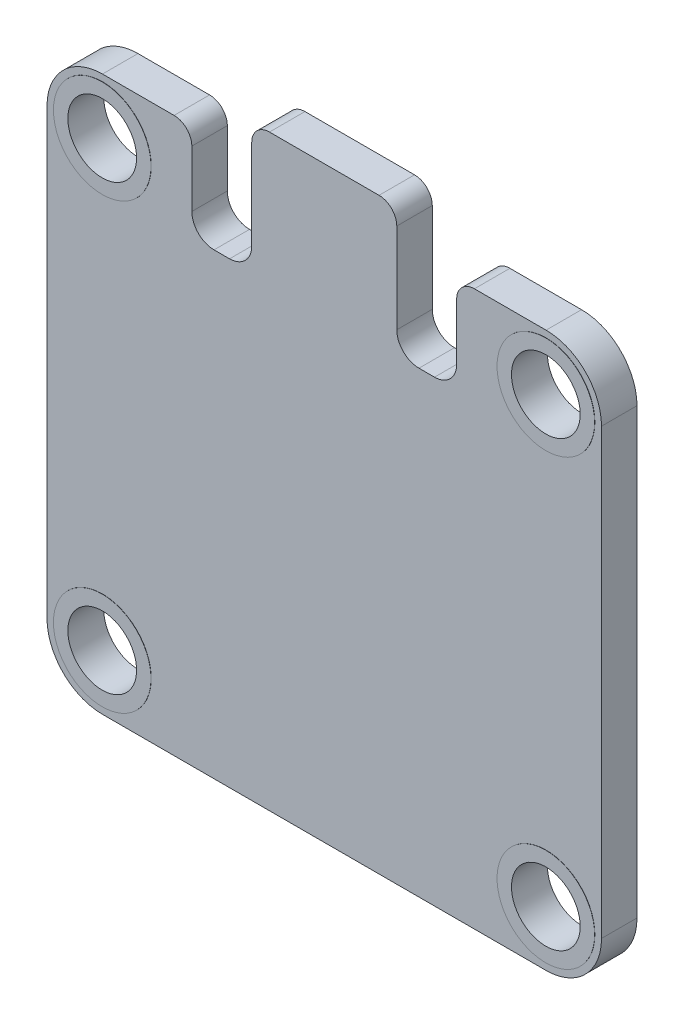
from build123d import *

# Parameters (mm, degrees)
SKETCH2_W                                  = 25
SKETCH2_H                                  = 25
BOSS_EXTRUDE1_MODULE_PCB_DEPTH             = 1.6
FILLET1_CORNERS_R                          = 2.5
SKETCH3_R                                  = 1.55
CUT_EXTRUDE1_FIRST_MH_DEPTH                = 1.6
SKETCH4_R                                  = 2.2
SKETCH4_R_2                                = 1.55
BOSS_EXTRUDE2_PTH_FOR_FIRST_MH_DEPTH       = 0.01
MIRROR2_SECOND_MH_PTH_COPY_1_SKETCH_R      = 2.2
MIRROR2_SECOND_MH_PTH_COPY_1_SKETCH_R_2    = 1.55
MIRROR2_SECOND_MH_PTH_COPY_1_DEPTH         = 0.01
MIRROR3_REMAINING_MH_PTH_COPY_1_SKETC_R    = 1.55
MIRROR3_REMAINING_MH_PTH_COPY_1_DEPTH      = 1.6
MIRROR3_REMAINING_MH_PTH_COPY_2_SKETC_R    = 2.2
MIRROR3_REMAINING_MH_PTH_COPY_2_SKETC_R_2  = 1.55
MIRROR3_REMAINING_MH_PTH_COPY_2_DEPTH      = 0.01
MIRROR3_REMAINING_MH_PTH_COPY_3_SKETC_R    = 2.2
MIRROR3_REMAINING_MH_PTH_COPY_3_SKETC_R_2  = 1.55
MIRROR3_REMAINING_MH_PTH_COPY_3_DEPTH      = 0.01
MIRROR3_REMAINING_MH_PTH_COPY_4_SKETC_R    = 2.2
MIRROR3_REMAINING_MH_PTH_COPY_4_SKETC_R_2  = 1.55
MIRROR3_REMAINING_MH_PTH_COPY_4_DEPTH      = 0.01
BOSS_EXTRUDE1_REACH                        = 3.62
SKETCH5_W                                  = 6.54
SKETCH5_H                                  = 1.6
BOSS_EXTRUDE3_TIP_OF_EDGE_CONNECTOR_DEPTH  = 1.5
SKETCH6_W                                  = 2.7
SKETCH6_H                                  = 1.6
CUT_EXTRUDE2_SIDES_OF_EDGE_CONNECTOR_DEPTH = 4.35
FILLET2_TIP_OF_EDGE_CONNECTOR_R            = 0.8
FILLET3_BASE_OF_EDGE_CONNECTOR_R           = 1
FILLET4_ADJACENT_TO_EDGE_CONNECTOR_R       = 0.8


with BuildPart() as part:
    # Sketch2 → Boss-Extrude1 _module PCB (new body)
    with BuildSketch(Plane.XY):
        Rectangle(SKETCH2_W, SKETCH2_H)
    extrude(amount=BOSS_EXTRUDE1_MODULE_PCB_DEPTH)

    # Fillet1 _corners
    fillet1_corners_edges = [part.edges().sort_by_distance(p)[0] for p in [
        (12.5, -12.5, 0.8),
        (-12.5, -12.5, 0.8),
        (-12.5, 12.5, 0.8),
        (12.5, 12.5, 0.8),
    ]]
    fillet(fillet1_corners_edges, radius=FILLET1_CORNERS_R)

    # Sketch3 → Cut-Extrude1 _first MH (cut)
    with BuildSketch(Plane.XY):
        with Locations((10, 10)):
            Circle(SKETCH3_R)
    cut_extrude1_first_mh = extrude(amount=CUT_EXTRUDE1_FIRST_MH_DEPTH, mode=Mode.SUBTRACT)

    # Sketch4 → Boss-Extrude2 _PTH for first MH (add)
    with BuildSketch(Plane.XY):
        with Locations((10, 10)):
            Circle(SKETCH4_R)
        with Locations((10, 10)):
            Circle(SKETCH4_R_2, mode=Mode.SUBTRACT)
    boss_extrude2_pth_for_first_mh = extrude(amount=-BOSS_EXTRUDE2_PTH_FOR_FIRST_MH_DEPTH)

    # Mirror1 _PTH for first MH: Boss-Extrude2 _PTH for first MH across plane
    add(boss_extrude2_pth_for_first_mh.mirror(Plane.XY.offset(0.8)))

    # Mirror2 _second MH _ PTH: Cut-Extrude1 _first MH, Boss-Extrude2 _PTH for first MH across plane
    add(cut_extrude1_first_mh.mirror(Plane(origin=(0, 0, 0), x_dir=(0, 0, 1), z_dir=(1, 0, 0))), mode=Mode.SUBTRACT)
    add(boss_extrude2_pth_for_first_mh.mirror(Plane(origin=(0, 0, 0), x_dir=(0, 0, 1), z_dir=(1, 0, 0))))

    # Mirror2 _second MH _ PTH copy 1 sketch → Mirror2 _second MH _ PTH copy 1 (add)
    with BuildSketch(Plane(origin=(0, 0, 1.6), x_dir=(-1, 0, 0), z_dir=(0, 0, -1))):
        with Locations((10, 10)):
            Circle(MIRROR2_SECOND_MH_PTH_COPY_1_SKETCH_R)
        with Locations((10, 10)):
            Circle(MIRROR2_SECOND_MH_PTH_COPY_1_SKETCH_R_2, mode=Mode.SUBTRACT)
    extrude(amount=-MIRROR2_SECOND_MH_PTH_COPY_1_DEPTH)

    # Mirror3 _remaining MH _ PTH: Cut-Extrude1 _first MH, Boss-Extrude2 _PTH for first MH across plane
    add(cut_extrude1_first_mh.mirror(Plane.ZX), mode=Mode.SUBTRACT)
    add(boss_extrude2_pth_for_first_mh.mirror(Plane.ZX))

    # Mirror3 _remaining MH _ PTH copy 1 sketc → Mirror3 _remaining MH _ PTH copy 1 (cut)
    with BuildSketch(Plane(origin=(0, 0, 0), x_dir=(-1, 0, 0), z_dir=(0, 0, 1))):
        with Locations((10, 10)):
            Circle(MIRROR3_REMAINING_MH_PTH_COPY_1_SKETC_R)
    extrude(amount=MIRROR3_REMAINING_MH_PTH_COPY_1_DEPTH, mode=Mode.SUBTRACT)

    # Mirror3 _remaining MH _ PTH copy 2 sketc → Mirror3 _remaining MH _ PTH copy 2 (add)
    with BuildSketch(Plane(origin=(0, 0, 0), x_dir=(-1, 0, 0), z_dir=(0, 0, 1))):
        with Locations((10, 10)):
            Circle(MIRROR3_REMAINING_MH_PTH_COPY_2_SKETC_R)
        with Locations((10, 10)):
            Circle(MIRROR3_REMAINING_MH_PTH_COPY_2_SKETC_R_2, mode=Mode.SUBTRACT)
    extrude(amount=-MIRROR3_REMAINING_MH_PTH_COPY_2_DEPTH)

    # Mirror3 _remaining MH _ PTH copy 3 sketc → Mirror3 _remaining MH _ PTH copy 3 (add)
    with BuildSketch(Plane(origin=(0, 0, 1.6), x_dir=(-1, 0, 0), z_dir=(0, 0, -1))):
        with Locations((10, -10)):
            Circle(MIRROR3_REMAINING_MH_PTH_COPY_3_SKETC_R)
        with Locations((10, -10)):
            Circle(MIRROR3_REMAINING_MH_PTH_COPY_3_SKETC_R_2, mode=Mode.SUBTRACT)
    extrude(amount=-MIRROR3_REMAINING_MH_PTH_COPY_3_DEPTH)

    # Mirror3 _remaining MH _ PTH copy 4 sketc → Mirror3 _remaining MH _ PTH copy 4 (add)
    with BuildSketch(Plane(origin=(0, 0, 1.6), x_dir=(1, 0, 0), z_dir=(0, 0, -1))):
        with Locations((10, 10)):
            Circle(MIRROR3_REMAINING_MH_PTH_COPY_4_SKETC_R)
        with Locations((10, 10)):
            Circle(MIRROR3_REMAINING_MH_PTH_COPY_4_SKETC_R_2, mode=Mode.SUBTRACT)
    extrude(amount=-MIRROR3_REMAINING_MH_PTH_COPY_4_DEPTH)

    # Sketch7 → Boss-Extrude1 (add, up to next)
    with BuildSketch(Plane(origin=(0, 0, -0.01), x_dir=(-1, 0, 0), z_dir=(0, 0, -1)), mode=Mode.PRIVATE) as boss_extrude1_sk1:
        with BuildLine():
            Line((-10, -7.8), (-12.2, -7.8))
            Line((-12.2, -7.8), (-12.2, -10))
            ThreePointArc((-12.2, -10), (-11.555634919, -8.444365081), (-10, -7.8))
        make_face()
    boss_extrude1_tool1 = extrude(boss_extrude1_sk1.sketch, amount=-BOSS_EXTRUDE1_REACH, mode=Mode.PRIVATE) - part.part
    add(boss_extrude1_tool1.solids().sort_by_distance((11.708591, -8.291409, -0.01))[0])
    # Sketch7 → Boss-Extrude1 (add, up to next)
    with BuildSketch(Plane(origin=(0, 0, -0.01), x_dir=(-1, 0, 0), z_dir=(0, 0, -1)), mode=Mode.PRIVATE) as boss_extrude1_sk2:
        with BuildLine():
            Line((-10, -12.2), (-7.8, -12.2))
            Line((-7.8, -12.2), (-7.8, -10))
            ThreePointArc((-7.8, -10), (-8.444365081, -11.555634919), (-10, -12.2))
        make_face()
    boss_extrude1_tool2 = extrude(boss_extrude1_sk2.sketch, amount=-BOSS_EXTRUDE1_REACH, mode=Mode.PRIVATE) - part.part
    add(boss_extrude1_tool2.solids().sort_by_distance((8.291409, -11.708591, -0.01))[0])

    # Sketch5 → Boss-Extrude3 _tip of edge connector (add)
    with BuildSketch(Plane(origin=(0, 12.5, 0), x_dir=(1, 0, 0), z_dir=(0, 1, 0))):
        with Locations((0, -0.8)):
            Rectangle(SKETCH5_W, SKETCH5_H)
    extrude(amount=BOSS_EXTRUDE3_TIP_OF_EDGE_CONNECTOR_DEPTH)

    # Sketch6 → Cut-Extrude2 _sides of edge connector (cut)
    with BuildSketch(Plane(origin=(0, 12.5, 0), x_dir=(1, 0, 0), z_dir=(0, 1, 0))):
        with Locations((-4.62, -0.8)):
            Rectangle(SKETCH6_W, SKETCH6_H)
        with Locations((4.62, -0.8)):
            Rectangle(SKETCH6_W, SKETCH6_H)
    extrude(amount=-CUT_EXTRUDE2_SIDES_OF_EDGE_CONNECTOR_DEPTH, mode=Mode.SUBTRACT)

    # Fillet2 _tip of edge connector
    fillet2_tip_of_edge_connector_edges = [part.edges().sort_by_distance(p)[0] for p in [
        (3.27, 14, 0.8),
        (-3.27, 14, 0.8),
    ]]
    fillet(fillet2_tip_of_edge_connector_edges, radius=FILLET2_TIP_OF_EDGE_CONNECTOR_R)

    # Fillet3 _base of edge connector
    fillet3_base_of_edge_connector_edges = [part.edges().sort_by_distance(p)[0] for p in [
        (-3.27, 8.15, 0.8),
        (-5.97, 8.15, 0.8),
        (3.27, 8.15, 0.8),
        (5.97, 8.15, 0.8),
    ]]
    fillet(fillet3_base_of_edge_connector_edges, radius=FILLET3_BASE_OF_EDGE_CONNECTOR_R)

    # Fillet4 _adjacent to edge connector
    fillet4_adjacent_to_edge_connector_edges = [part.edges().sort_by_distance(p)[0] for p in [
        (-5.97, 12.5, 0.8),
        (5.97, 12.5, 0.8),
    ]]
    fillet(fillet4_adjacent_to_edge_connector_edges, radius=FILLET4_ADJACENT_TO_EDGE_CONNECTOR_R)


solid = part.part
